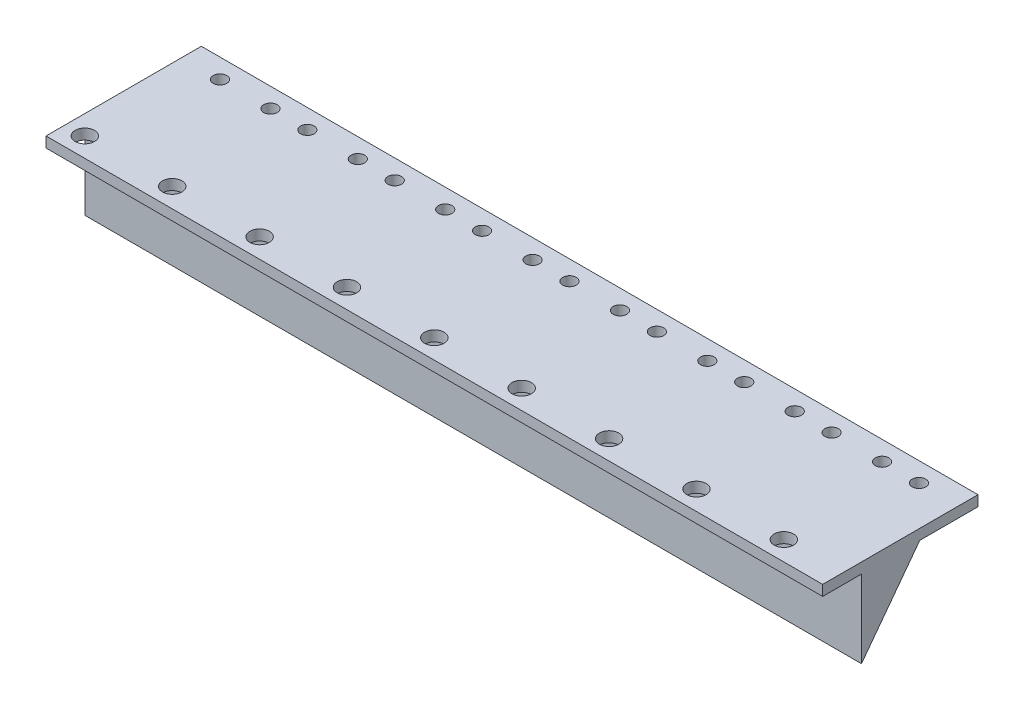
from build123d import *

# Parameters (mm, degrees)
SKETCH1_W           = 200
SKETCH1_H           = 40
BOSS_EXTRUDE1_DEPTH = 2.7
SKETCH2_R           = 1.75
CUT_EXTRUDE1_DEPTH  = 3.7
SKETCH3_R           = 1.75
CUT_EXTRUDE2_DEPTH  = 3.7
SKETCH4_R           = 1.75
CUT_EXTRUDE3_DEPTH  = 3.7
SKETCH5_R           = 1.75
CUT_EXTRUDE4_DEPTH  = 3.7
LPATTERN2_COUNT     = 2
LPATTERN2_PITCH     = 9.5
SKETCH6_R           = 1.75
CUT_EXTRUDE5_DEPTH  = 3.7
SKETCH7_R           = 1.75
CUT_EXTRUDE6_DEPTH  = 3.7
SKETCH8_R           = 2.5
CUT_EXTRUDE7_DEPTH  = 3.7
LPATTERN3_COUNT     = 9
LPATTERN3_PITCH     = 22.5
BOSS_EXTRUDE2_DEPTH = 200


with BuildPart() as part:
    # Sketch1 → Boss-Extrude1 (new body)
    with BuildSketch(Plane(origin=(0, 0, 0), x_dir=(1, 0, 0), z_dir=(0, 1, 0))):
        Rectangle(SKETCH1_W, SKETCH1_H)
    extrude(amount=BOSS_EXTRUDE1_DEPTH)

    # Sketch2 → Cut-Extrude1 (cut, through all)
    with BuildSketch(Plane(origin=(0, 2.7, 0), x_dir=(1, 0, 0), z_dir=(0, 1, 0))):
        with Locations((-90.2, 15)):
            Circle(SKETCH2_R)
    extrude(amount=-CUT_EXTRUDE1_DEPTH, mode=Mode.SUBTRACT)

    # Sketch3 → Cut-Extrude2 (cut, through all)
    with BuildSketch(Plane(origin=(0, 2.7, 0), x_dir=(1, 0, 0), z_dir=(0, 1, 0))):
        with Locations((-77.2, 15)):
            Circle(SKETCH3_R)
    extrude(amount=-CUT_EXTRUDE2_DEPTH, mode=Mode.SUBTRACT)

    # Sketch4 → Cut-Extrude3 (cut, through all)
    with BuildSketch(Plane(origin=(0, 2.7, 0), x_dir=(1, 0, 0), z_dir=(0, 1, 0))):
        with Locations((-67.7, 15)):
            Circle(SKETCH4_R)
    extrude(amount=-CUT_EXTRUDE3_DEPTH, mode=Mode.SUBTRACT)

    # Sketch5 → Cut-Extrude4 (cut, through all)
    with BuildSketch(Plane(origin=(0, 2.7, 0), x_dir=(1, 0, 0), z_dir=(0, 1, 0))):
        with Locations((-54.7, 15)):
            Circle(SKETCH5_R)
    cut_extrude4 = extrude(amount=-CUT_EXTRUDE4_DEPTH, mode=Mode.SUBTRACT)

    # LPattern2: Cut-Extrude4 ×2
    with Locations(*[(i * LPATTERN2_PITCH, 0, 0) for i in range(1, LPATTERN2_COUNT)]):
        add(cut_extrude4, mode=Mode.SUBTRACT)

    # Sketch6 → Cut-Extrude5 (cut, through all)
    with BuildSketch(Plane(origin=(0, 2.7, 0), x_dir=(1, 0, 0), z_dir=(0, 1, 0))):
        with Locations((-32.2, 15)):
            Circle(SKETCH6_R)
        with Locations((-22.7, 15)):
            Circle(SKETCH6_R)
    extrude(amount=-CUT_EXTRUDE5_DEPTH, mode=Mode.SUBTRACT)

    # Sketch7 → Cut-Extrude6 (cut, through all)
    with BuildSketch(Plane(origin=(0, 2.7, 0), x_dir=(1, 0, 0), z_dir=(0, 1, 0))):
        with Locations((-9.7, 15)):
            Circle(SKETCH7_R)
        with Locations((-0.2, 15)):
            Circle(SKETCH7_R)
        with Locations((12.8, 15)):
            Circle(SKETCH7_R)
        with Locations((22.3, 15)):
            Circle(SKETCH7_R)
        with Locations((35.3, 15)):
            Circle(SKETCH7_R)
        with Locations((44.8, 15)):
            Circle(SKETCH7_R)
        with Locations((57.8, 15)):
            Circle(SKETCH7_R)
        with Locations((67.3, 15)):
            Circle(SKETCH7_R)
        with Locations((80.3, 15)):
            Circle(SKETCH7_R)
        with Locations((89.8, 15)):
            Circle(SKETCH7_R)
    extrude(amount=-CUT_EXTRUDE6_DEPTH, mode=Mode.SUBTRACT)

    # Sketch8 → Cut-Extrude7 (cut, through all)
    with BuildSketch(Plane(origin=(0, 2.7, 0), x_dir=(1, 0, 0), z_dir=(0, 1, 0))):
        with Locations((-95, -15)):
            Circle(SKETCH8_R)
    cut_extrude7 = extrude(amount=-CUT_EXTRUDE7_DEPTH, mode=Mode.SUBTRACT)

    # LPattern3: Cut-Extrude7 ×9
    with Locations(*[(i * LPATTERN3_PITCH, 0, 0) for i in range(1, LPATTERN3_COUNT)]):
        add(cut_extrude7, mode=Mode.SUBTRACT)

    # Sketch10 → Boss-Extrude2 (add)
    with BuildSketch(Plane(origin=(100, 0, 0), x_dir=(0, 0, -1), z_dir=(1, 0, 0))):
        Polygon((-10, 0), (-10, -20), (5, 0), align=None)
    extrude(amount=-BOSS_EXTRUDE2_DEPTH)


solid = part.part
